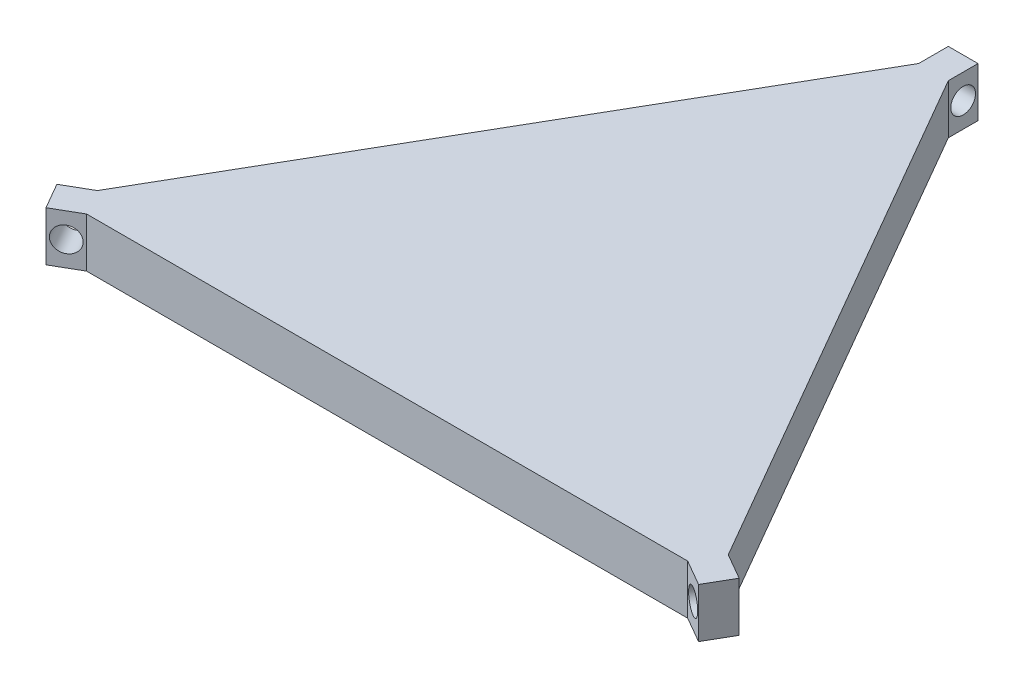
from build123d import *

# Parameters (mm, degrees)
BOSS_EXTRUDE1_DEPTH = 10
SKETCH2_R           = 2.5
CUT_EXTRUDE1_DEPTH  = 134.326025
SKETCH3_R           = 2.5
CUT_EXTRUDE2_DEPTH  = 6


with BuildPart() as part:
    # Sketch1 → Boss-Extrude1 (new body)
    with BuildSketch(Plane(origin=(0, 0, 0), x_dir=(1, 0, 0), z_dir=(0, 1, 0))):
        Polygon((-3, 110.383597966), (-63.73, 5.196152423), (-68.926152423, 2.196152423), (-65.926152423, -3), (-60.73, 0), (60.73, 0), (65.926152423, -3), (68.926152423, 2.196152423), (63.73, 5.196152423), (3, 110.383597966), (3, 116.383597966), (-3, 116.383597966), align=None)
    extrude(amount=BOSS_EXTRUDE1_DEPTH)

    # Sketch2 → Cut-Extrude1 (cut)
    with BuildSketch(Plane(origin=(-15.1825, 0, -26.296861386), x_dir=(0.866025404, 0, -0.5), z_dir=(0.5, 0, 0.866025404))):
        with Locations((-55.593722772, 5)):
            Circle(SKETCH2_R)
    cut_extrude1 = extrude(amount=-CUT_EXTRUDE1_DEPTH, mode=Mode.SUBTRACT)

    # Mirror6: Cut-Extrude1 across plane
    add(cut_extrude1.mirror(Plane.ZY), mode=Mode.SUBTRACT)

    # Sketch3 → Cut-Extrude2 (cut)
    with BuildSketch(Plane.ZY.offset(2.999999999)):
        with Locations((-113.383597966, 5)):
            Circle(SKETCH3_R)
    extrude(amount=-CUT_EXTRUDE2_DEPTH, mode=Mode.SUBTRACT)


solid = part.part
